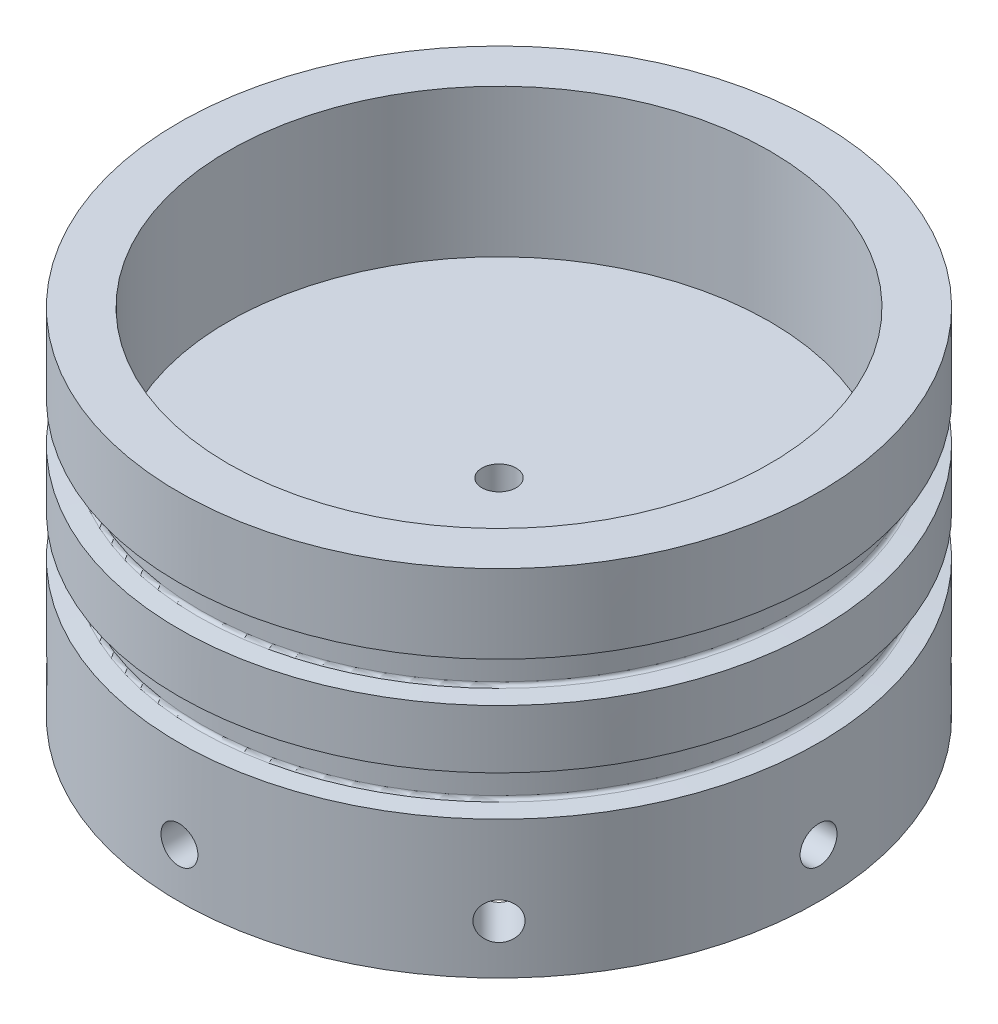
from build123d import *

# Parameters (mm, degrees)
LPATTERN1_COUNT                     = 2
LPATTERN1_PITCH                     = 12.7
F_3_16_0_1875_DIAMETER_HOLE1_REACH  = 102.34
F_3_16_0_1875_DIAMETER_HOLE1_BORE_R = 2.38125
CIRPATTERN1_COUNT                   = 8


with BuildPart() as part:
    # Sketch1 → Revolve1 (revolve)
    with BuildSketch(Plane.XY, mode=Mode.PRIVATE) as revolve1_sk:
        Polygon((-41.275, 13.97), (-41.275, 45.72), (-34.925, 45.72), (-34.925, 26.67), (-2.2098, 26.67), (-2.2098, 1.4986), (-3.683, 0.0254), (-3.683, 0), (-5.1435, 0), (-5.1435, 13.97), (-34.925, 13.97), (-34.925, 0), (-41.275, 0), align=None)
    revolve(revolve1_sk.sketch.rotate(Axis((0, 0, 0), (0, 1, 0)), 270), axis=Axis((0, 0, 0), (0, 1, 0)))

    # Sketch3 → Groove for AS 568-234_ O-Ring1 (revolve, cut)
    with BuildSketch(Plane(origin=(0, 0, 0), x_dir=(0, 0, -1), z_dir=(-1, 0, 0)), mode=Mode.PRIVATE) as groove_for_as_568_234_o_ring1_sk:
        with BuildLine():
            Line((38.861359272, -30.6451), (41.3639, -30.426156056))
            Line((41.3639, -30.426156056), (41.3639, -35.613843944))
            Line((41.3639, -35.613843944), (38.861359272, -35.3949))
            ThreePointArc((38.861359272, -35.3949), (38.572380224, -35.252391304), (38.4556, -34.952091457))
            Line((38.4556, -34.952091457), (38.4556, -31.087908543))
            ThreePointArc((38.4556, -31.087908543), (38.572380224, -30.787608696), (38.861359272, -30.6451))
        make_face()
    groove_for_as_568_234_o_ring1 = revolve(groove_for_as_568_234_o_ring1_sk.sketch.rotate(Axis((0, -50, 0), (0, 1, 0)), 180), axis=Axis((0, -50, 0), (0, 1, 0)), mode=Mode.SUBTRACT)

    # LPattern1: Groove for AS 568-234_ O-Ring1 ×2
    with Locations(*[(0, -i * LPATTERN1_PITCH, 0) for i in range(1, LPATTERN1_COUNT)]):
        add(groove_for_as_568_234_o_ring1, mode=Mode.SUBTRACT)

    # 3_16 _0.1875_ Diameter Hole1 bore (on position points) → 3_16 _0.1875_ Diameter Hole1 (cut, up to next)
    with BuildSketch(Plane(origin=(41.275, 6.35, 0), x_dir=(0, 0, 1), z_dir=(1, 0, 0)), mode=Mode.PRIVATE) as f_3_16_0_1875_diameter_hole1_sk1:
        Circle(F_3_16_0_1875_DIAMETER_HOLE1_BORE_R)
    f_3_16_0_1875_diameter_hole1_tool1 = extrude(f_3_16_0_1875_diameter_hole1_sk1.sketch, amount=-F_3_16_0_1875_DIAMETER_HOLE1_REACH, mode=Mode.PRIVATE) & part.part
    f_3_16_0_1875_diameter_hole1 = f_3_16_0_1875_diameter_hole1_tool1.solids().sort_by_distance((41.275, 6.35, 0))[0]
    add(f_3_16_0_1875_diameter_hole1, mode=Mode.SUBTRACT)

    # CirPattern1: 3_16 _0.1875_ Diameter Hole1 ×8 about axis
    cirpattern1_axis = Axis((0, -2.286, 0), (0, 1, 0))
    for i in range(1, CIRPATTERN1_COUNT):
        add(f_3_16_0_1875_diameter_hole1.rotate(cirpattern1_axis, i * 360 / CIRPATTERN1_COUNT), mode=Mode.SUBTRACT)


solid = part.part
